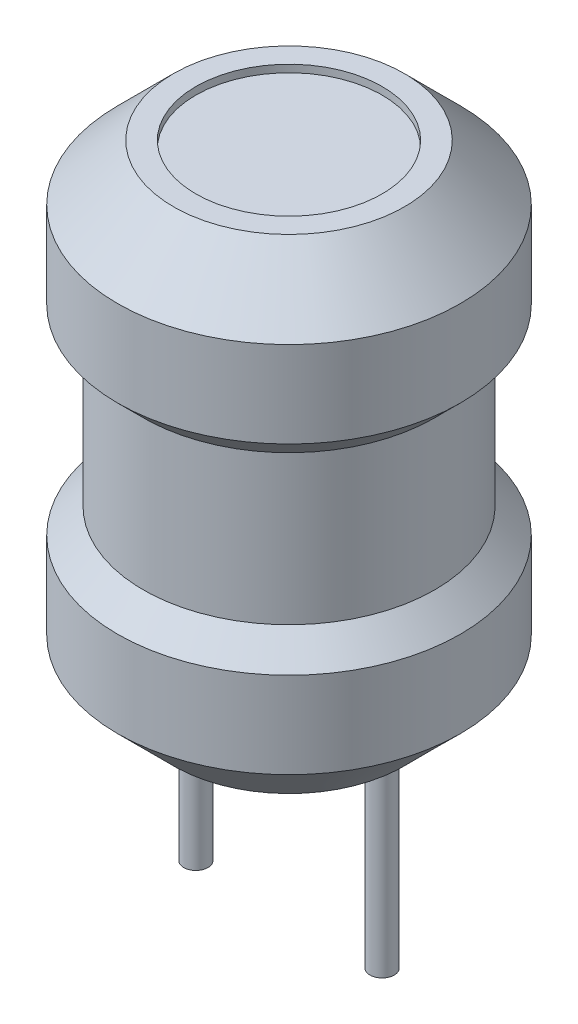
from build123d import *

# Parameters (mm, degrees)
SKETCH_7_R          = 0.325
EXTRUDE_1_DEPTH     = 5
SKETCH_8_R          = 2.5
CUT_EXTRUDE_1_DEPTH = 0.2


with BuildPart() as part:
    # Эскиз6 → Повернуть1 (revolve)
    with BuildSketch(Plane.XY):
        Polygon((0, 13), (0, 0), (3.1, 0), (4.6, 1.5), (4.6, 3.812414318), (3.912414318, 4.5), (3.912414318, 8.5), (4.6, 9.187585682), (4.6, 11.5), (3.1, 13), align=None)
    revolve(axis=Axis((0, 13, 0), (0, -1, 0)))

    # Эскиз7 → Бобышка-Вытянуть1 (add)
    with BuildSketch(Plane.XZ):
        with Locations((2.5, 0)):
            Circle(SKETCH_7_R)
        with Locations((-2.5, 0)):
            Circle(SKETCH_7_R)
    extrude(amount=EXTRUDE_1_DEPTH)

    # Эскиз8 → Вырез-Вытянуть1 (cut)
    with BuildSketch(Plane(origin=(0, 13, 0), x_dir=(1, 0, 0), z_dir=(0, 1, 0))):
        Circle(SKETCH_8_R)
    extrude(amount=-CUT_EXTRUDE_1_DEPTH, mode=Mode.SUBTRACT)


solid = part.part
